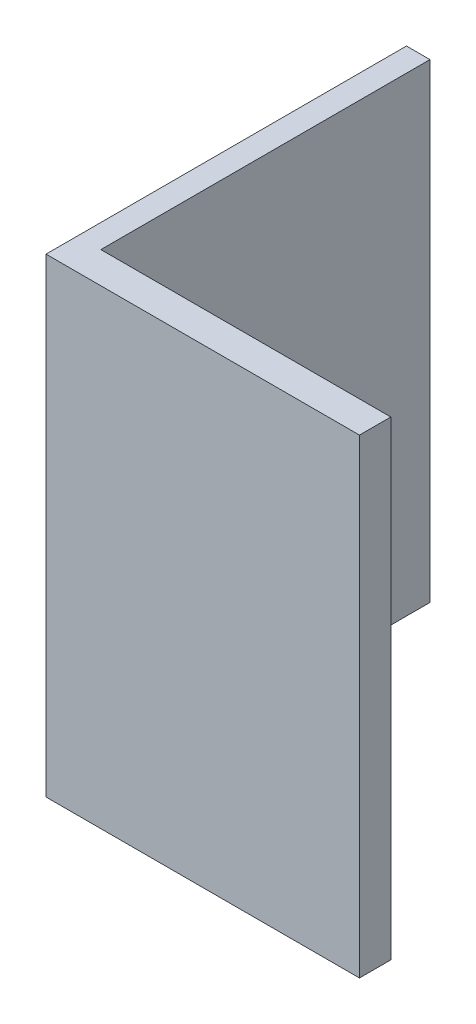
from build123d import *

# Parameters (mm, degrees)
EXTRUDE_1_DEPTH = 30


with BuildPart() as part:
    # 草图1 → 凸台-拉伸1 (new body)
    with BuildSketch(Plane(origin=(0, 0, 0), x_dir=(1, 0, 0), z_dir=(0, 1, 0))):
        Polygon((-16.605624487, 20.943203819), (-16.605624487, -2.056796181), (3.394375513, -2.056796181), (3.394375513, -0.056796181), (-15.105624487, -0.056796181), (-15.105624487, 20.943203819), align=None)
    extrude(amount=EXTRUDE_1_DEPTH)


solid = part.part
